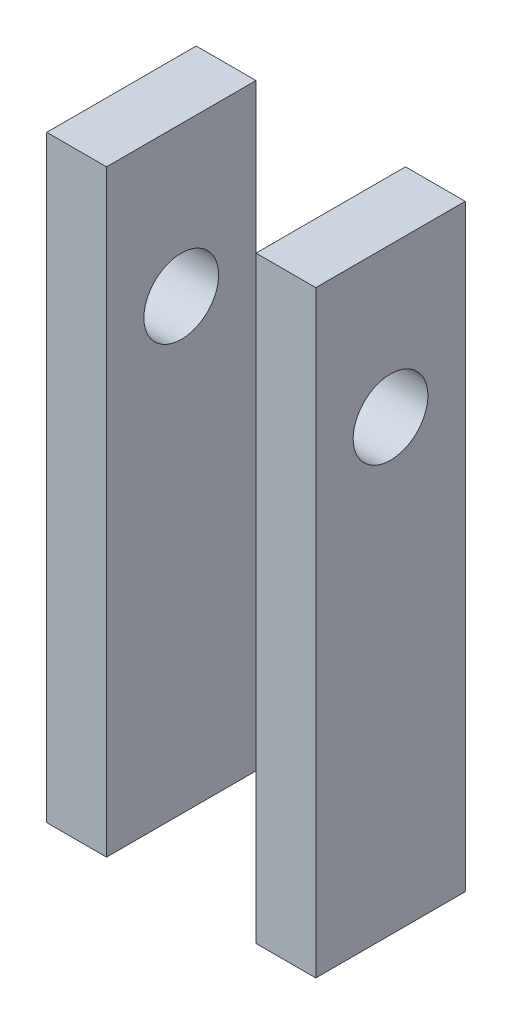
from build123d import *

# Parameters (mm, degrees)
SKETCH1_W             = 5.08
SKETCH1_H             = 12.7
BOSS_EXTRUDE1_DEPTH   = 50.8
BOSS_EXTRUDE1_2_DEPTH = 50.8
SKETCH2_R             = 3.175
CUT_EXTRUDE1_DEPTH    = 23.86


with BuildPart() as part:
    # Sketch1 → Boss-Extrude1 (new body)
    with BuildSketch(Plane(origin=(0, 0, 0), x_dir=(1, 0, 0), z_dir=(0, 1, 0))):
        with Locations((-8.89, 0)):
            Rectangle(SKETCH1_W, SKETCH1_H)
    extrude(amount=BOSS_EXTRUDE1_DEPTH)


with BuildPart() as body_2:
    # Sketch1 → Boss-Extrude1 2 (new body)
    with BuildSketch(Plane(origin=(0, 0, 0), x_dir=(1, 0, 0), z_dir=(0, 1, 0))):
        with Locations((8.89, 0)):
            Rectangle(SKETCH1_W, SKETCH1_H)
    extrude(amount=BOSS_EXTRUDE1_2_DEPTH)


with BuildPart() as cut_extrude1_tool:
    # Sketch2 → Cut-Extrude1 (new body, through all)
    with BuildSketch(Plane.ZY.offset(11.43)):
        with Locations((0, 38.1)):
            Circle(SKETCH2_R)
    extrude(amount=-CUT_EXTRUDE1_DEPTH)


with BuildPart() as part_1:
    add(part.part)

    # Cut-Extrude1: cut by cut_extrude1_tool
    add(cut_extrude1_tool.part, mode=Mode.SUBTRACT)


with BuildPart() as body_2_1:
    add(body_2.part)

    # Cut-Extrude1: cut by cut_extrude1_tool
    add(cut_extrude1_tool.part, mode=Mode.SUBTRACT)


solid = Compound([part_1.part, body_2_1.part])
